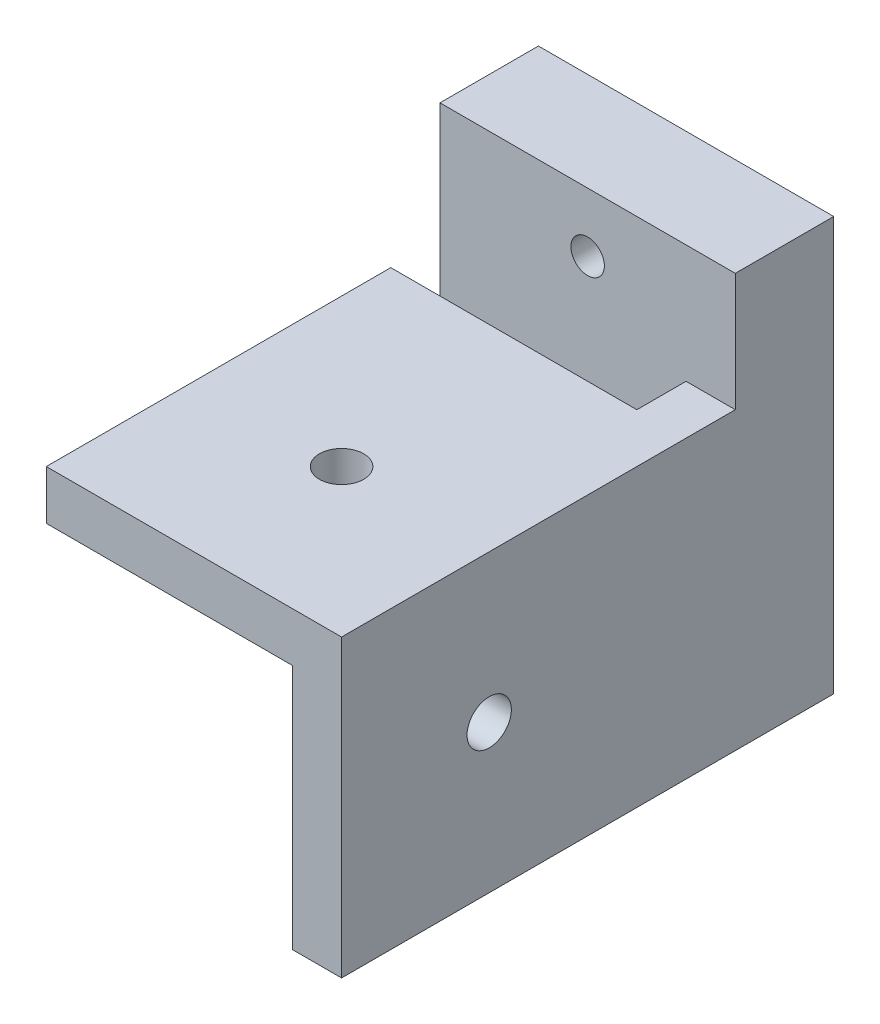
from build123d import *

# Parameters (mm, degrees)
ESBO_O1_W                                           = 30
ESBO_O1_H                                           = 30
RESSALTO_EXTRUS_O1_DEPTH                            = 50
ESBO_O2_W                                           = 25
ESBO_O2_H                                           = 5
CORTE_EXTRUS_O1_DEPTH                               = 31
CORTE_EXTRUS_O2_START                               = -5
ESBO_O3_W                                           = 25
ESBO_O3_H                                           = 25
CORTE_EXTRUS_O2_DEPTH                               = 26
FURO_COM_FOLGA_DE_M41_D                             = 4.5
FURO_COM_FOLGA_DE_M41_ON_FACE_2_D                   = 4.5
ESBO_O5_W                                           = 30
ESBO_O5_H                                           = 10
RESSALTO_EXTRUS_O2_DEPTH                            = 12
REBAIXO_PARA_PARAFUSO_COM_CABE_A_PANELA_D           = 3.4
REBAIXO_PARA_PARAFUSO_COM_CABE_A_PANELA_CBORE_D     = 7
REBAIXO_PARA_PARAFUSO_COM_CABE_A_PANELA_CBORE_DEPTH = 2.4


with BuildPart() as part:
    # Esboço1 → Ressalto-extrusão1 (new body)
    with BuildSketch(Plane.XY):
        with Locations((-15, 15)):
            Rectangle(ESBO_O1_W, ESBO_O1_H)
    extrude(amount=RESSALTO_EXTRUS_O1_DEPTH)

    # Esboço2 → Corte-extrusão1 (cut, through all)
    with BuildSketch(Plane(origin=(0, 30, 0), x_dir=(1, 0, 0), z_dir=(0, 1, 0))):
        with Locations((-17.5, -12.5)):
            Rectangle(ESBO_O2_W, ESBO_O2_H)
    extrude(amount=-CORTE_EXTRUS_O1_DEPTH, mode=Mode.SUBTRACT)

    # Esboço3 → Corte-extrusão2 (cut, through all)
    with BuildSketch(Plane(origin=(0, 30, 0), x_dir=(1, 0, 0), z_dir=(0, 1, 0)).offset(CORTE_EXTRUS_O2_START)):
        with Locations((-17.5, -37.5)):
            Rectangle(ESBO_O3_W, ESBO_O3_H)
    extrude(amount=-CORTE_EXTRUS_O2_DEPTH, mode=Mode.SUBTRACT)

    # Furo com folga de M41 (through all)
    with Locations(Plane(origin=(-5, 15, 35), x_dir=(0, 0, -1), z_dir=(-1, 0, 0))):
        with Locations((0, 0)):
            Hole(FURO_COM_FOLGA_DE_M41_D / 2)

    # Furo com folga de M41 on face 2 (through all)
    with Locations(Plane(origin=(-15, 25, 35), x_dir=(0, 0, -1), z_dir=(0, -1, 0))):
        with Locations((0, 0)):
            Hole(FURO_COM_FOLGA_DE_M41_ON_FACE_2_D / 2)

    # Esboço5 → Ressalto-extrusão2 (add)
    with BuildSketch(Plane(origin=(0, 30, 0), x_dir=(1, 0, 0), z_dir=(0, 1, 0))):
        with Locations((-15, -5)):
            Rectangle(ESBO_O5_W, ESBO_O5_H)
    extrude(amount=RESSALTO_EXTRUS_O2_DEPTH)

    # Rebaixo para parafuso com cabeça panela de M31 (through all)
    with Locations(Plane(origin=(0, 0, 0), x_dir=(-1, 0, 0), z_dir=(0, 0, -1))):
        with Locations((15, 36)):
            CounterBoreHole(REBAIXO_PARA_PARAFUSO_COM_CABE_A_PANELA_D / 2, REBAIXO_PARA_PARAFUSO_COM_CABE_A_PANELA_CBORE_D / 2, REBAIXO_PARA_PARAFUSO_COM_CABE_A_PANELA_CBORE_DEPTH)


solid = part.part
